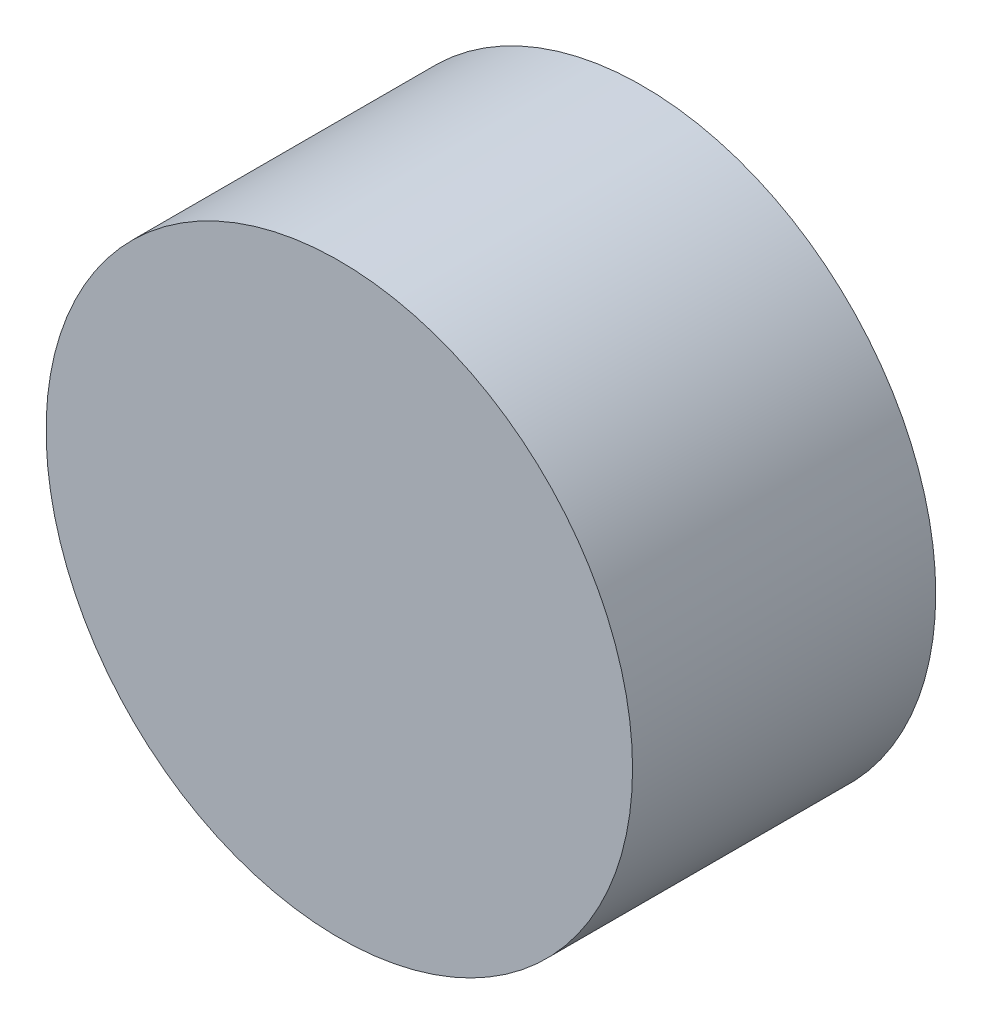
from build123d import *

# Parameters (mm, degrees)
SKETCH1_R           = 14.75
BOSS_EXTRUDE1_DEPTH = 15.25


with BuildPart() as part:
    # Sketch1 → Boss-Extrude1 (new body)
    with BuildSketch(Plane.XY):
        Circle(SKETCH1_R)
    extrude(amount=BOSS_EXTRUDE1_DEPTH)


solid = part.part
